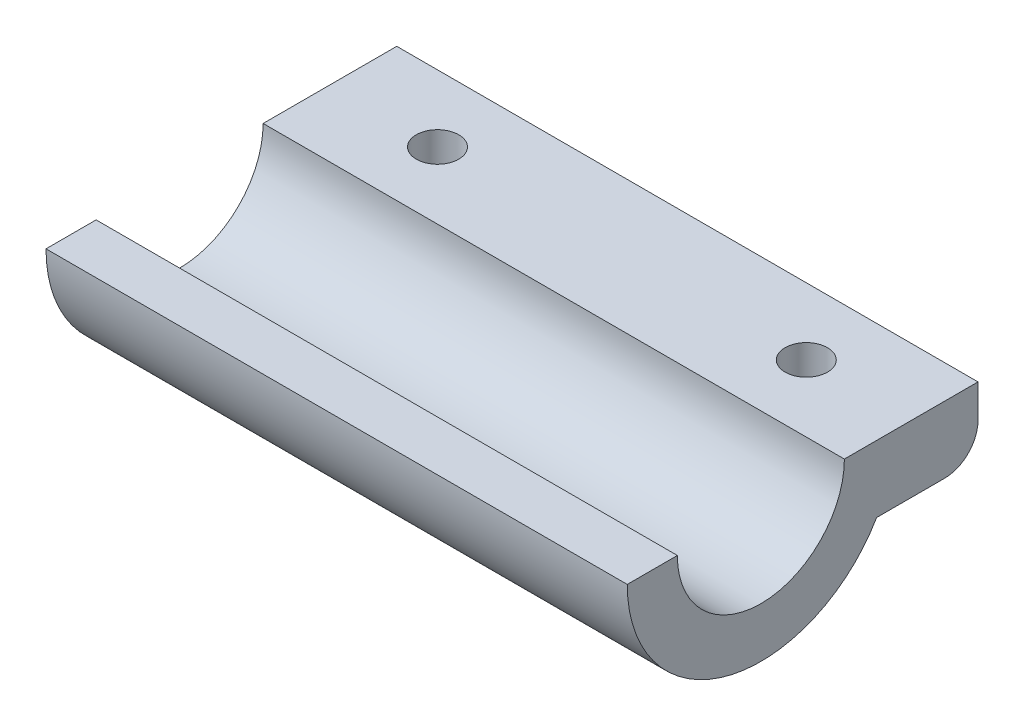
from build123d import *

# Parameters (mm, degrees)
BOSS_EXTRUDE1_DEPTH = 87
SKETCH2_R           = 3.175
CUT_EXTRUDE1_DEPTH  = 21
FILLET1_R           = 5


with BuildPart() as part:
    # Sketch1 → Boss-Extrude1 (new body)
    with BuildSketch(Plane(origin=(0, 0, 0), x_dir=(0, 0, -1), z_dir=(1, 0, 0))):
        with BuildLine():
            Line((-32.5, 0), (-25, 0))
            ThreePointArc((-25, 0), (-12.5, -12.5), (0, 0))
            Line((0, 0), (20, 0))
            Line((20, 0), (20, -10))
            Line((20, -10), (4.820508076, -10))
            ThreePointArc((4.820508076, -10), (-17.676380902, -19.318516526), (-32.5, 0))
        make_face()
    extrude(amount=BOSS_EXTRUDE1_DEPTH)

    # Sketch2 → Cut-Extrude1 (cut, through all)
    with BuildSketch(Plane(origin=(0, 0, 0), x_dir=(1, 0, 0), z_dir=(0, 1, 0))):
        with Locations((71.3, 10)):
            Circle(SKETCH2_R)
        with Locations((16.1, 10)):
            Circle(SKETCH2_R)
    extrude(amount=-CUT_EXTRUDE1_DEPTH, mode=Mode.SUBTRACT)

    # Fillet1
    fillet1_edges = [part.edges().sort_by_distance(p)[0] for p in [
        (43.5, -10, -20),
    ]]
    fillet(fillet1_edges, radius=FILLET1_R)


solid = part.part
